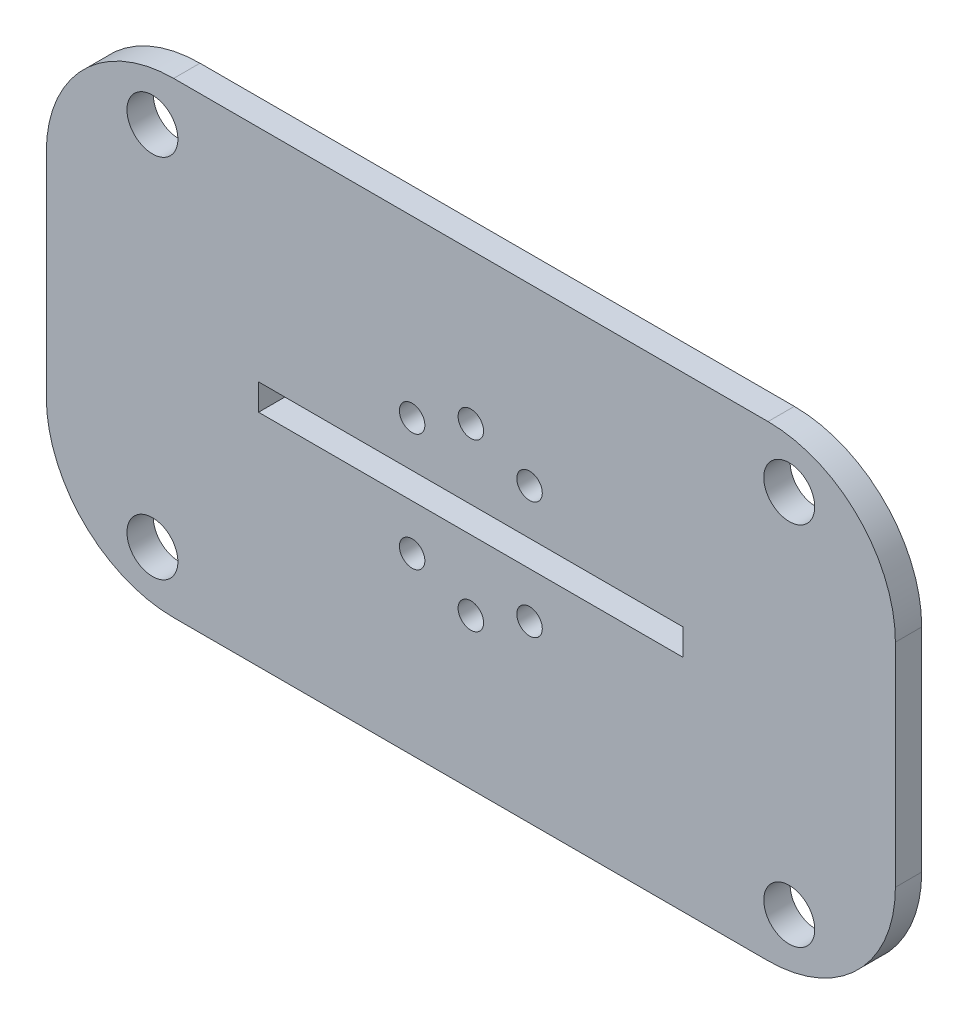
from build123d import *

# Parameters (mm, degrees)
SKETCH1_W           = 100
SKETCH1_H           = 55
SKETCH1_R           = 3
SKETCH1_W_2         = 50
SKETCH1_H_2         = 3.1
BOSS_EXTRUDE1_DEPTH = 3.1
SKETCH2_R           = 1.5
CUT_EXTRUDE1_DEPTH  = 4.1
FILLET1_R           = 15


with BuildPart() as part:
    # Sketch1 → Boss-Extrude1 (new body)
    with BuildSketch(Plane.XY):
        Rectangle(SKETCH1_W, SKETCH1_H)
        with Locations((37.5, 21.55)):
            Circle(SKETCH1_R, mode=Mode.SUBTRACT)
        with Locations((-37.5, 21.55)):
            Circle(SKETCH1_R, mode=Mode.SUBTRACT)
        with Locations((-37.5, -21.55)):
            Circle(SKETCH1_R, mode=Mode.SUBTRACT)
        with Locations((37.5, -21.55)):
            Circle(SKETCH1_R, mode=Mode.SUBTRACT)
        Rectangle(SKETCH1_W_2, SKETCH1_H_2, mode=Mode.SUBTRACT)
    extrude(amount=BOSS_EXTRUDE1_DEPTH)

    # Sketch2 → Cut-Extrude1 (cut, through all)
    with BuildSketch(Plane.XY.offset(3.1)):
        with Locations((-6.914797213, 6.914797213)):
            Circle(SKETCH2_R)
        with Locations((0, 9.779)):
            Circle(SKETCH2_R)
        with Locations((6.914797213, 6.914797213)):
            Circle(SKETCH2_R)
        with Locations((9.779, 0)):
            Circle(SKETCH2_R)
        with Locations((6.914797213, -6.914797213)):
            Circle(SKETCH2_R)
        with Locations((0, -9.779)):
            Circle(SKETCH2_R)
        with Locations((-6.914797213, -6.914797213)):
            Circle(SKETCH2_R)
        with Locations((-9.779, 0)):
            Circle(SKETCH2_R)
    extrude(amount=-CUT_EXTRUDE1_DEPTH, mode=Mode.SUBTRACT)

    # Fillet1
    fillet1_edges = [part.edges().sort_by_distance(p)[0] for p in [
        (50, -27.5, 1.55),
        (-50, -27.5, 1.55),
        (-50, 27.5, 1.55),
        (50, 27.5, 1.55),
    ]]
    fillet(fillet1_edges, radius=FILLET1_R)


solid = part.part
